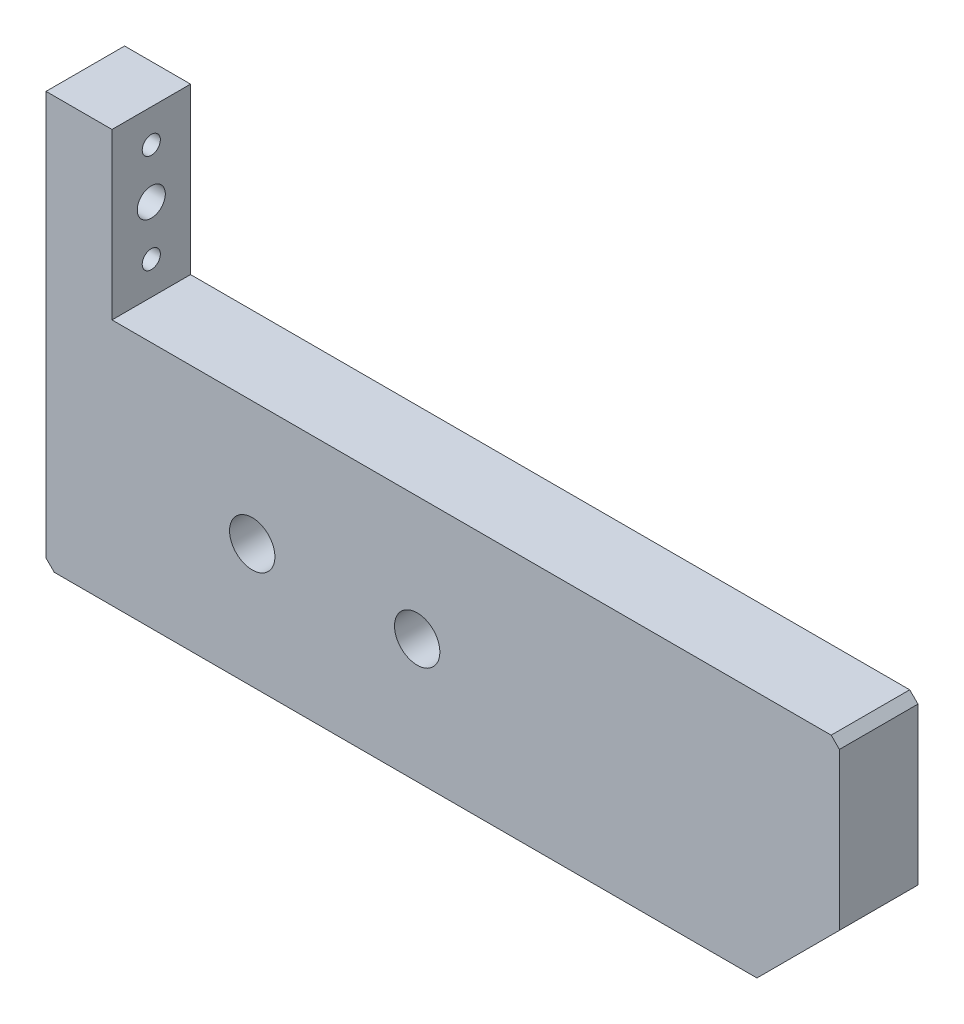
from build123d import *

# Parameters (mm, degrees)
SKETCH1_R                = 2.75
BOSS_EXTRUDE1_DEPTH      = 1
BOSS_EXTRUDE1_DEPTH_BACK = 8.525
CHAMFER1_SIZE            = 10
CHAMFER2_SIZE            = 1
SKETCH2_R                = 1.7
CUT_EXTRUDE1_DEPTH       = 97.192388155
SKETCH3_R                = 1.1
CUT_EXTRUDE2_DEPTH       = 97.192388155
SKETCH4_R                = 3.175
CUT_EXTRUDE3_DEPTH       = 3


with BuildPart() as part:
    # Sketch1 → Boss-Extrude1 (new body, two sides)
    with BuildSketch(Plane.XY) as boss_extrude1_sk:
        Polygon((-1071, 209.41125497), (-1071, 239.41125497), (-1159.192388155, 239.41125497), (-1159.192388155, 259.41125497), (-1167.192388155, 259.41125497), (-1167.192388155, 209.41125497), align=None)
        with Locations((-1122.192388155, 224.41125497)):
            Circle(SKETCH1_R, mode=Mode.SUBTRACT)
        with Locations((-1142.192388155, 224.41125497)):
            Circle(SKETCH1_R, mode=Mode.SUBTRACT)
    extrude(amount=BOSS_EXTRUDE1_DEPTH)
    extrude(boss_extrude1_sk.sketch, amount=-BOSS_EXTRUDE1_DEPTH_BACK)

    # Chamfer1
    chamfer1_edges = [part.edges().sort_by_distance(p)[0] for p in [
        (-1071, 209.41125497, -3.7625),
    ]]
    chamfer(chamfer1_edges, length=CHAMFER1_SIZE)

    # Chamfer2
    chamfer2_edges = [part.edges().sort_by_distance(p)[0] for p in [
        (-1167.192388155, 209.41125497, -3.7625),
        (-1071, 239.41125497, -3.7625),
    ]]
    chamfer(chamfer2_edges, length=CHAMFER2_SIZE)

    # Sketch2 → Cut-Extrude1 (cut, through all)
    with BuildSketch(Plane.ZY.offset(1167.192388155)):
        with Locations((-3.762499999, 249.41125497)):
            Circle(SKETCH2_R)
    extrude(amount=-CUT_EXTRUDE1_DEPTH, mode=Mode.SUBTRACT)

    # Sketch3 → Cut-Extrude2 (cut, through all)
    with BuildSketch(Plane.ZY.offset(1167.192388155)):
        with Locations((-3.762499999, 255.41125497)):
            Circle(SKETCH3_R)
        with Locations((-3.762499999, 243.41125497)):
            Circle(SKETCH3_R)
    extrude(amount=-CUT_EXTRUDE2_DEPTH, mode=Mode.SUBTRACT)

    # Sketch4 → Cut-Extrude3 (cut)
    with BuildSketch(Plane.ZY.offset(1167.192388155)):
        with Locations((-3.762499999, 249.41125497)):
            Circle(SKETCH4_R)
    extrude(amount=-CUT_EXTRUDE3_DEPTH, mode=Mode.SUBTRACT)


solid = part.part
